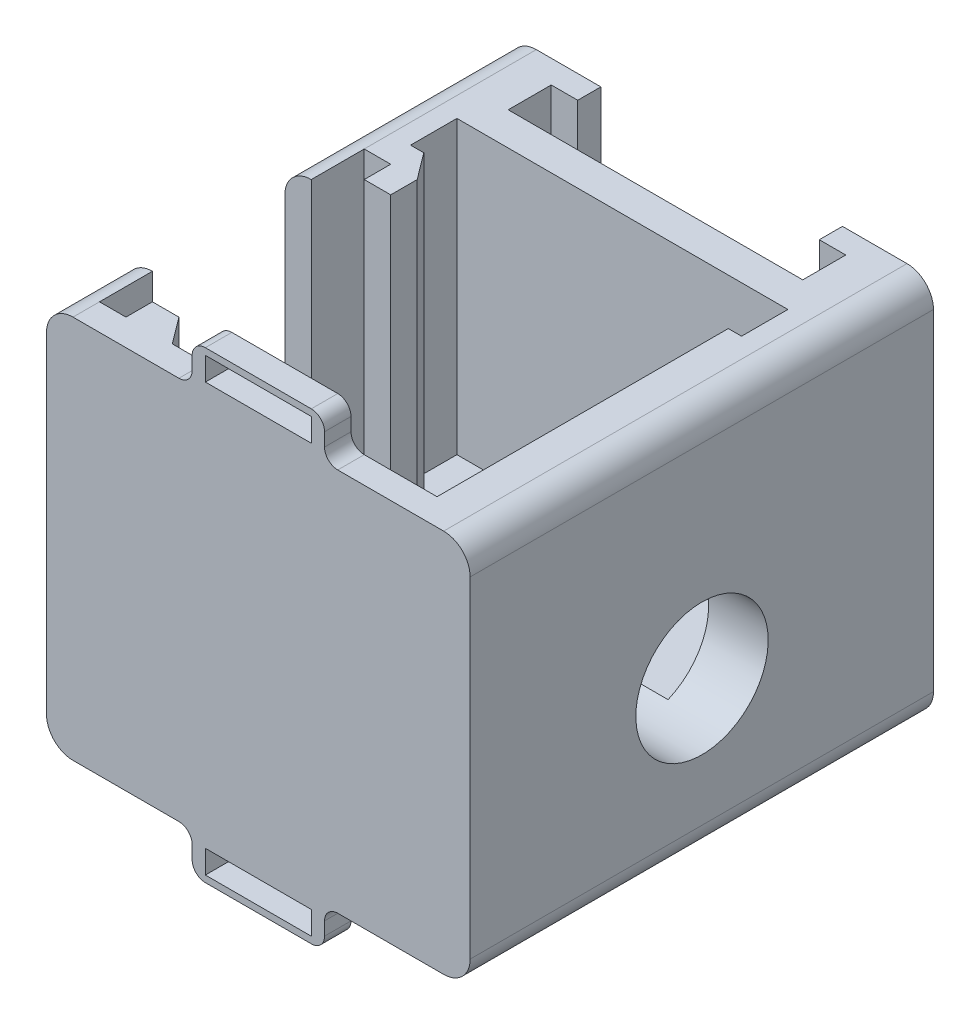
from build123d import *

# Parameters (mm, degrees)
SKETCH1_W                = 32
SKETCH1_H                = 29
BOSS_EXTRUDE1_DEPTH      = 35
FILLET1_R                = 2
SLOT_FOR_COIL_DEPTH      = 1
SLOT_FOR_COIL_DEPTH_BACK = 30
BOSS_EXTRUDE2_DEPTH      = 7
BOSS_EXTRUDE3_DEPTH      = 1.75
SKETCH5_W                = 2
SKETCH5_H                = 7
CUT_EXTRUDE2_DEPTH       = 33
CUT_EXTRUDE3_DEPTH       = 22
SKETCH7_W                = 2
SKETCH7_H                = 33
BOSS_EXTRUDE4_DEPTH      = 0.25
FILLET2_R                = 6
CUT_EXTRUDE5_DEPTH       = 4.5
SKETCH14_W               = 2.5
SKETCH14_H               = 20
CUT_EXTRUDE6_DEPTH       = 22
SKETCH16_W               = 2
SKETCH16_H               = 2
BOSS_EXTRUDE5_DEPTH      = 22
BOSS_EXTRUDE6_DEPTH      = 22
SKETCH21_W               = 10
SKETCH21_H               = 2
BOSS_EXTRUDE7_DEPTH      = 3
SKETCH23_W               = 8
SKETCH23_H               = 1.75
CUT_EXTRUDE7_DEPTH       = 2
FILLET3_R                = 1
CUT_EXTRUDE8_REACH       = 34
SKETCH26_R               = 5


with BuildPart() as part:
    # Sketch1 → Boss-Extrude1 (new body)
    with BuildSketch(Plane.XY):
        Rectangle(SKETCH1_W, SKETCH1_H)
    extrude(amount=BOSS_EXTRUDE1_DEPTH)

    # Fillet1
    fillet1_edges = [part.edges().sort_by_distance(p)[0] for p in [
        (16, -14.5, 17.5),
        (-16, -14.5, 17.5),
        (-16, 14.5, 17.5),
        (16, 14.5, 17.5),
    ]]
    fillet(fillet1_edges, radius=FILLET1_R)

    # Sketch2 → Slot for Coil (cut, two sides)
    with BuildSketch(Plane.XZ.offset(14.5)) as slot_for_coil_sk:
        Polygon((-9.125, 0), (-9.125, 1.75), (-11.125, 1.75), (-11.125, 5), (11.125, 5), (11.125, 1.75), (9.125, 1.75), (9.125, 0), align=None)
    extrude(amount=SLOT_FOR_COIL_DEPTH, mode=Mode.SUBTRACT)
    extrude(slot_for_coil_sk.sketch, amount=-SLOT_FOR_COIL_DEPTH_BACK, mode=Mode.SUBTRACT)

    # Sketch3 → Boss-Extrude2 (add)
    with BuildSketch(Plane.XZ.offset(14.5)):
        Polygon((-9.125, 0), (-9.125, 1.75), (-11.125, 1.75), (-11.125, 5), (11.125, 5), (11.125, 1.75), (9.125, 1.75), (9.125, 0), align=None)
    extrude(amount=-BOSS_EXTRUDE2_DEPTH)

    # Sketch4 → Boss-Extrude3 (add)
    with BuildSketch(Plane(origin=(0, 0, 1.75), x_dir=(-1, 0, 0), z_dir=(0, 0, -1))):
        with BuildLine():
            Line((-9.125, 7.5), (-9.125, 6.5))
            ThreePointArc((-9.125, 6.5), (-8.875, 7), (-9.125, 7.5))
        make_face()
    boss_extrude3 = extrude(amount=BOSS_EXTRUDE3_DEPTH)

    # Mirror1: Boss-Extrude3 across plane
    add(boss_extrude3.mirror(Plane(origin=(0, 0, 0), x_dir=(0, 0, 1), z_dir=(1, 0, 0))))

    # Sketch5 → Cut-Extrude2 (cut)
    with BuildSketch(Plane(origin=(0, 0, 0), x_dir=(-1, 0, 0), z_dir=(0, 0, -1))):
        with Locations((0, -11)):
            Rectangle(SKETCH5_W, SKETCH5_H)
    extrude(amount=-CUT_EXTRUDE2_DEPTH, mode=Mode.SUBTRACT)

    # Sketch6 → Cut-Extrude3 (cut)
    with BuildSketch(Plane(origin=(0, 14.5, 0), x_dir=(1, 0, 0), z_dir=(0, 1, 0))):
        Polygon((-12.5, -7.5), (-12.5, -11), (-11.5, -11), (-11.5, -33), (11.5, -33), (11.5, -11), (12.5, -11), (12.5, -7.5), align=None)
    extrude(amount=-CUT_EXTRUDE3_DEPTH, mode=Mode.SUBTRACT)

    # Sketch7 → Boss-Extrude4 (add)
    with BuildSketch(Plane.XZ.offset(14.5)):
        with Locations((0, 16.5)):
            Rectangle(SKETCH7_W, SKETCH7_H)
    extrude(amount=-BOSS_EXTRUDE4_DEPTH)

    # Fillet2
    fillet2_edges = [part.edges().sort_by_distance(p)[0] for p in [
        (0, -14.25, 33),
    ]]
    fillet(fillet2_edges, radius=FILLET2_R)

    # Sketch11 → Cut-Extrude5 (cut)
    with BuildSketch(Plane(origin=(-16, 0, 44), x_dir=(0, 0, -1), z_dir=(1, 0, 0))):
        with BuildLine():
            Line((27, 25), (27, 0))
            ThreePointArc((27, 0), (21, -6), (15, 0))
            Line((15, 0), (15, 25))
            ThreePointArc((15, 25), (21, 31), (27, 25))
        make_face()
    extrude(amount=CUT_EXTRUDE5_DEPTH, mode=Mode.SUBTRACT)

    # Sketch14 → Cut-Extrude6 (cut)
    with BuildSketch(Plane(origin=(0, 14.5, 0), x_dir=(1, 0, 0), z_dir=(0, 1, 0))):
        with Locations((-12.75, -23)):
            Rectangle(SKETCH14_W, SKETCH14_H)
    extrude(amount=-CUT_EXTRUDE6_DEPTH, mode=Mode.SUBTRACT)

    # Sketch16 → Boss-Extrude5 (add)
    with BuildSketch(Plane(origin=(0, 14.5, 0), x_dir=(1, 0, 0), z_dir=(0, 1, 0))):
        with Locations((-11, -14)):
            Rectangle(SKETCH16_W, SKETCH16_H)
        with Locations((-11, -32)):
            Rectangle(SKETCH16_W, SKETCH16_H)
    extrude(amount=-BOSS_EXTRUDE5_DEPTH)

    # Sketch20 → Boss-Extrude6 (add)
    with BuildSketch(Plane(origin=(0, 14.5, 0), x_dir=(1, 0, 0), z_dir=(0, 1, 0))):
        Polygon((-11.5, -11), (-10, -13), (-11.5, -13), align=None)
        Polygon((-10, -31), (-8.5, -33), (-10, -33), align=None)
    extrude(amount=-BOSS_EXTRUDE6_DEPTH)

    # Sketch21 → Boss-Extrude7 (add)
    with BuildSketch(Plane(origin=(0, 14.5, 0), x_dir=(-1, 0, 0), z_dir=(0, 1, 0))):
        with Locations((0, 34)):
            Rectangle(SKETCH21_W, SKETCH21_H)
    boss_extrude7 = extrude(amount=BOSS_EXTRUDE7_DEPTH)

    # Sketch23 → Cut-Extrude7 (cut)
    with BuildSketch(Plane.XY.offset(35)):
        with Locations((0, 16.125)):
            Rectangle(SKETCH23_W, SKETCH23_H)
    cut_extrude7 = extrude(amount=-CUT_EXTRUDE7_DEPTH, mode=Mode.SUBTRACT)

    # Mirror3: Boss-Extrude7, Cut-Extrude7 across plane
    add(boss_extrude7.mirror(Plane.ZX))
    add(cut_extrude7.mirror(Plane.ZX), mode=Mode.SUBTRACT)

    # Fillet3
    fillet3_edges = [part.edges().sort_by_distance(p)[0] for p in [
        (5, 14.5, 34),
        (-5, 14.5, 34),
        (5, 17.5, 34),
        (-5, 17.5, 34),
        (5, -17.5, 34),
        (-5, -17.5, 34),
        (5, -14.5, 34),
        (-5, -14.5, 34),
    ]]
    fillet(fillet3_edges, radius=FILLET3_R)

    # Sketch26 → Cut-Extrude8 (cut, up to next)
    with BuildSketch(Plane(origin=(16, 0, 0), x_dir=(0, 0, -1), z_dir=(1, 0, 0)), mode=Mode.PRIVATE) as cut_extrude8_sk1:
        with Locations((-17.485, -2.89)):
            Circle(SKETCH26_R)
    cut_extrude8_tool1 = extrude(cut_extrude8_sk1.sketch, amount=-CUT_EXTRUDE8_REACH, mode=Mode.PRIVATE) & part.part
    add(cut_extrude8_tool1.solids().sort_by_distance((16, -2.89, 17.485))[0], mode=Mode.SUBTRACT)


solid = part.part
